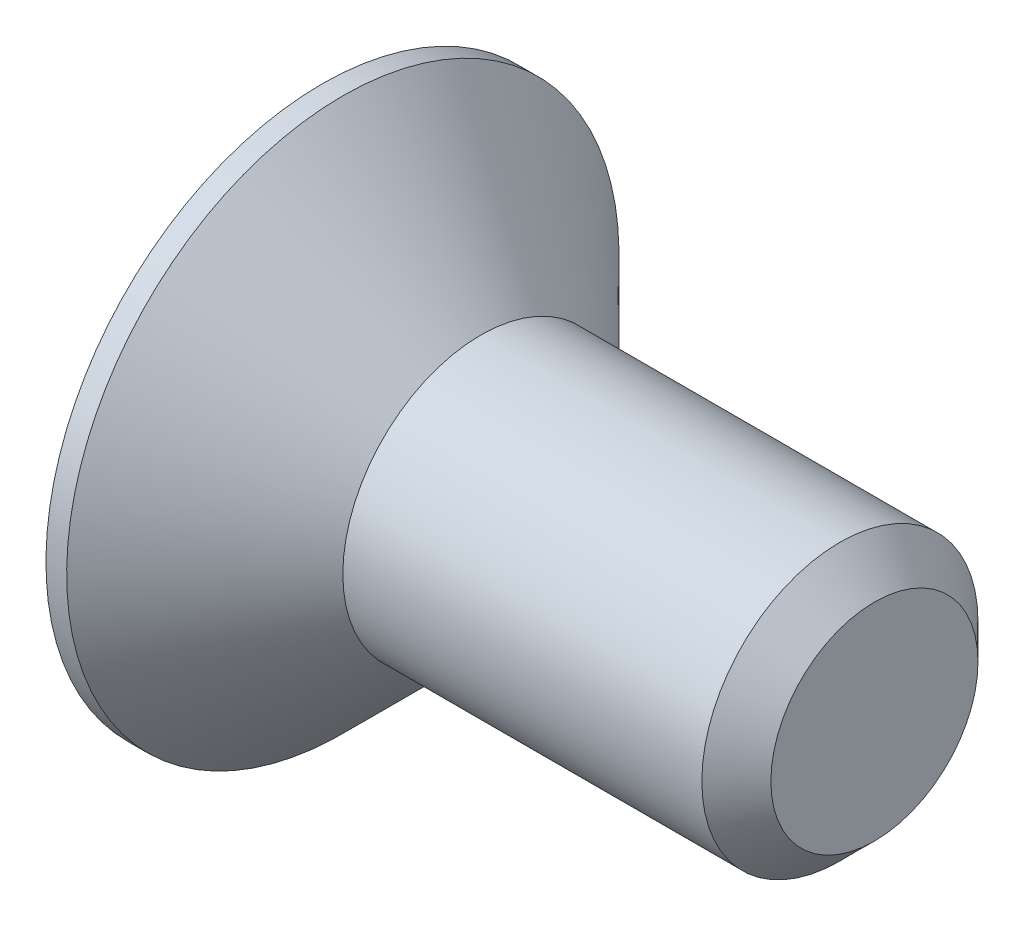
from build123d import *

# Parameters (mm, degrees)
CHANFREIN1_SIZE         = 0.5
ENL_V_MAT_EXTRU_1_DEPTH = 1.8


with BuildPart() as part:
    # Esquisse1 → Révolution1 (revolve)
    with BuildSketch(Plane.XY):
        Polygon((0, 0), (0, 4), (0.3, 4), (2.3, 2), (8, 2), (8, 0), align=None)
    revolve(axis=Axis((8, 0, 0), (-1, 0, 0)))

    # Chanfrein1
    chanfrein1_edges = [part.edges().sort_by_distance(p)[0] for p in [
        (8, -2, 0),
    ]]
    chamfer(chanfrein1_edges, length=CHANFREIN1_SIZE)

    # Esquisse2 → Enlèv. mat.-Extru.1 (cut)
    with BuildSketch(Plane.ZY):
        Polygon((0, 1.443375673), (-1.25, 0.721687836), (-1.25, -0.721687836), (0, -1.443375673), (1.25, -0.721687836), (1.25, 0.721687836), align=None)
    extrude(amount=-ENL_V_MAT_EXTRU_1_DEPTH, mode=Mode.SUBTRACT)


solid = part.part
